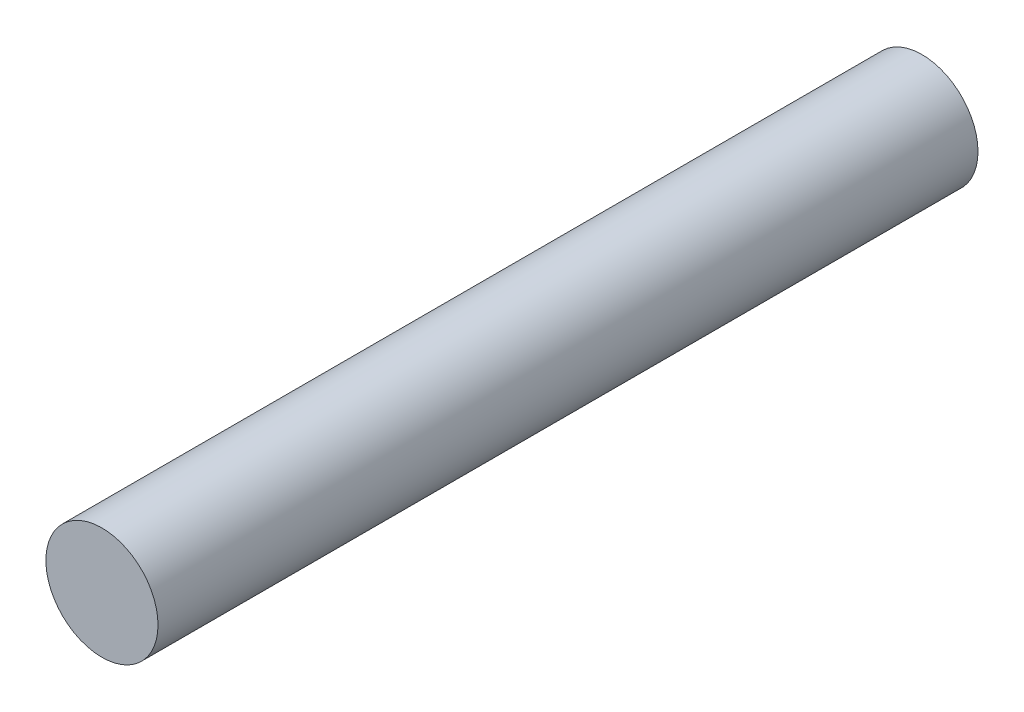
from build123d import *

# Parameters (mm, degrees)
SKETCH1_R      = 2.3876
EXTRUDE1_DEPTH = 17.4625


with BuildPart() as part:
    # Sketch1 → Extrude1 (new body, symmetric)
    with BuildSketch(Plane.XY):
        Circle(SKETCH1_R)
    extrude(amount=EXTRUDE1_DEPTH, both=True)


solid = part.part
